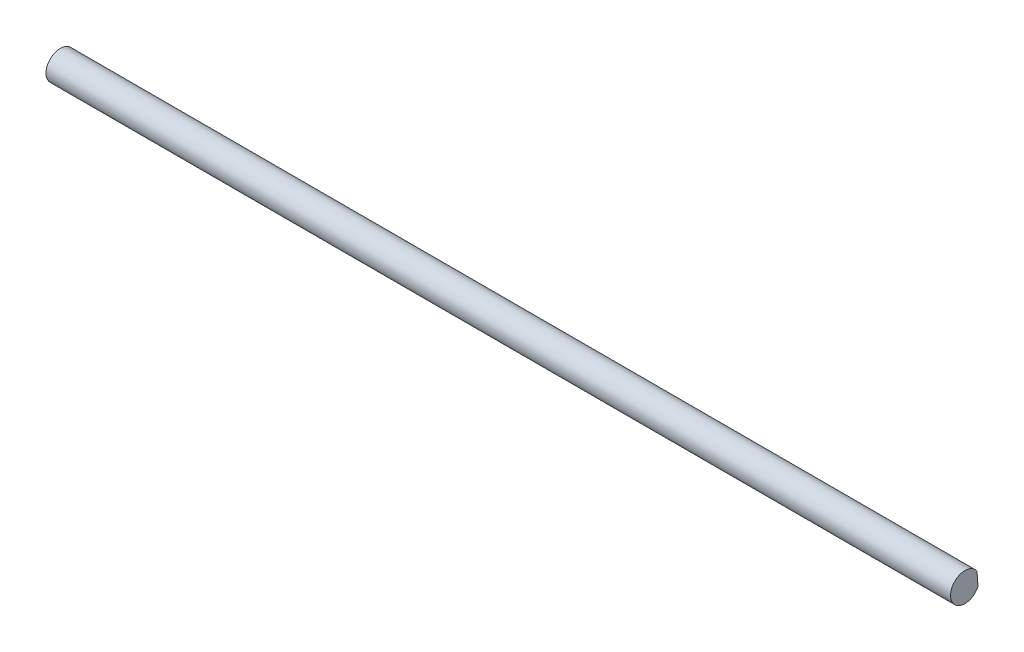
from build123d import *

# Parameters (mm, degrees)
BOSS_EXTRU_1_DEPTH = 200


with BuildPart() as part:
    # Esquisse1 → Boss.-Extru.1 (new body)
    with BuildSketch(Plane(origin=(0, 0, 0), x_dir=(0, 0, -1), z_dir=(1, 0, 0))):
        with BuildLine():
            Line((2.891496859, -1.31143849), (2.683155312, 1.697440006))
            ThreePointArc((2.683155312, 1.697440006), (-3.167416006, -0.219319043), (2.891496859, -1.31143849))
        make_face()
    extrude(amount=BOSS_EXTRU_1_DEPTH)


solid = part.part
